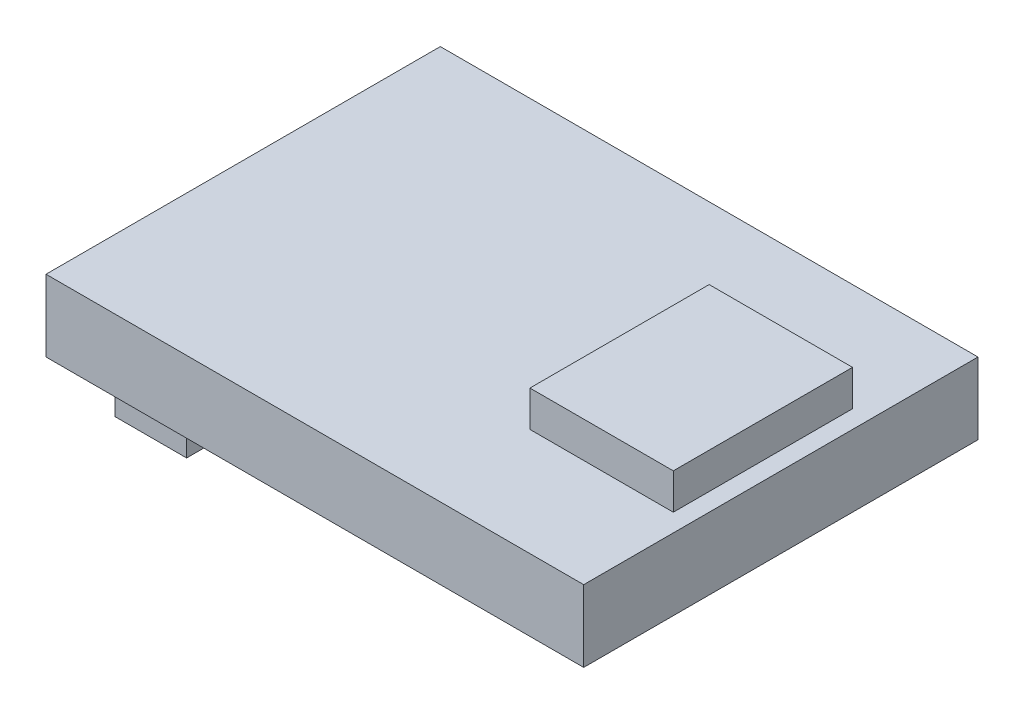
from build123d import *

# Parameters (mm, degrees)
SKETCH_1_W      = 15
SKETCH_1_H      = 11
EXTRUDE_1_DEPTH = 2
SKETCH_2_W      = 4
SKETCH_2_H      = 5
EXTRUDE_2_DEPTH = 1
SKETCH_3_W      = 2
SKETCH_3_H      = 7.956602162
EXTRUDE_3_DEPTH = 2


with BuildPart() as part:
    # 스케치1 → 보스-돌출1 (new body)
    with BuildSketch(Plane(origin=(0, 0, 0), x_dir=(1, 0, 0), z_dir=(0, 1, 0))):
        Rectangle(SKETCH_1_W, SKETCH_1_H)
    extrude(amount=EXTRUDE_1_DEPTH)

    # 스케치2 → 보스-돌출2 (add)
    with BuildSketch(Plane(origin=(0, 2, 0), x_dir=(1, 0, 0), z_dir=(0, 1, 0))):
        with Locations((5, 0)):
            Rectangle(SKETCH_2_W, SKETCH_2_H)
    extrude(amount=EXTRUDE_2_DEPTH)

    # 스케치3 → 보스-돌출3 (add)
    with BuildSketch(Plane.XZ):
        with Locations((-6.098780992, 0)):
            Rectangle(SKETCH_3_W, SKETCH_3_H)
    extrude(amount=EXTRUDE_3_DEPTH)


solid = part.part
